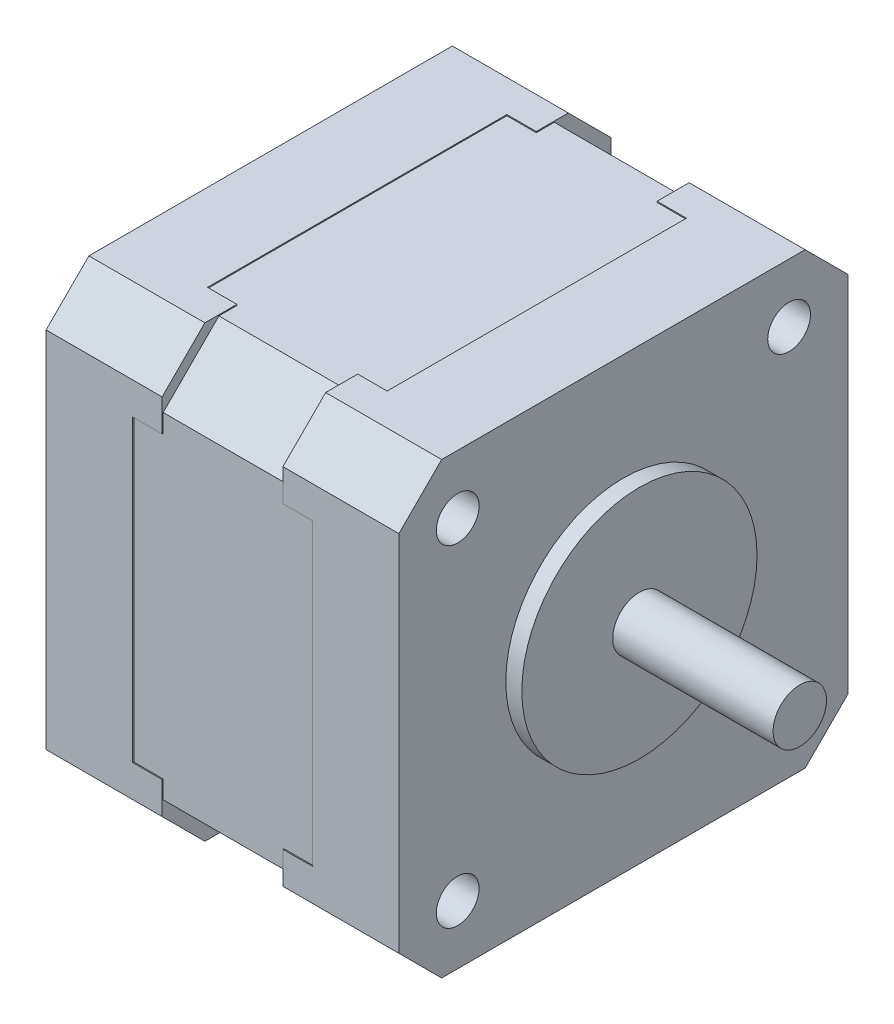
from build123d import *

# Parameters (mm, degrees)
CROQUIS1_W                  = 41.8
CROQUIS1_H                  = 41.8
SALIENTE_EXTRUIR1_DEPTH     = 11.3
CROQUIS2_W                  = 42
CROQUIS2_H                  = 41.9
SALIENTE_EXTRUIR2_DEPTH     = 10.85
CROQUIS3_W                  = 10.85
CROQUIS3_H                  = 42
SALIENTE_EXTRUIR3_DEPTH     = 0.1
CROQUIS4_W                  = 42
CROQUIS4_H                  = 42
SALIENTE_EXTRUIR4_DEPTH     = 10.85
CORTAR_EXTRUIR1_REACH       = 26.9
CROQUIS5_W                  = 0.1
CROQUIS5_H                  = 28
CORTAR_EXTRUIR2_REACH       = 26.9
CROQUIS6_W                  = 28
CROQUIS6_H                  = 0.1
CROQUIS7_W                  = 2.75
CROQUIS7_H                  = 28
CORTAR_EXTRUIR3_DEPTH       = 0.1
CROQUIS8_W                  = 2.75
CROQUIS8_H                  = 28
CORTAR_EXTRUIR4_DEPTH       = 0.1
CROQUIS9_W                  = 28
CROQUIS9_H                  = 0.1
CORTAR_EXTRUIR5_DEPTH       = 2.75
CROQUIS10_W                 = 2.75
CROQUIS10_H                 = 28
CORTAR_EXTRUIR6_DEPTH       = 0.1
CROQUIS11_W                 = 2.75
CROQUIS11_H                 = 28
CORTAR_EXTRUIR7_DEPTH       = 0.1
CROQUIS12_W                 = 2.75
CROQUIS12_H                 = 28
CORTAR_EXTRUIR8_DEPTH       = 0.1
CHAFL_N1_SIZE               = 5.214213562
CHAFL_N2_SIZE               = 4
CROQUIS18_R                 = 2
CORTAR_EXTRUIR10_DEPTH      = 6
CORTAR_EXTRUIR10_DEPTH_BACK = 3


with BuildPart() as part:
    # Croquis1 → Saliente-Extruir1 (new body)
    with BuildSketch(Plane(origin=(-5.65, 0, 0), x_dir=(0, -1, 0), z_dir=(-1, 0, 0))):
        Rectangle(CROQUIS1_W, CROQUIS1_H)
    extrude(amount=-SALIENTE_EXTRUIR1_DEPTH)

    # Croquis2 → Saliente-Extruir2 (add)
    with BuildSketch(Plane(origin=(5.65, 0, 0), x_dir=(0, 0, -1), z_dir=(1, 0, 0))):
        with Locations((0, -0.05)):
            Rectangle(CROQUIS2_W, CROQUIS2_H)
    extrude(amount=SALIENTE_EXTRUIR2_DEPTH)

    # Croquis3 → Saliente-Extruir3 (add)
    with BuildSketch(Plane(origin=(0, 20.9, 0), x_dir=(-1, 0, 0), z_dir=(0, 1, 0))):
        with Locations((-11.075, 0)):
            Rectangle(CROQUIS3_W, CROQUIS3_H)
    extrude(amount=SALIENTE_EXTRUIR3_DEPTH)

    # Croquis4 → Saliente-Extruir4 (add)
    with BuildSketch(Plane(origin=(-5.65, 0, 0), x_dir=(0, 0, -1), z_dir=(1, 0, 0))):
        Rectangle(CROQUIS4_W, CROQUIS4_H)
    extrude(amount=-SALIENTE_EXTRUIR4_DEPTH)

    # Croquis5 → Cortar-Extruir1 (cut, up to next)
    with BuildSketch(Plane(origin=(8.4, 0, 0), x_dir=(0, 0, -1), z_dir=(1, 0, 0)), mode=Mode.PRIVATE) as cortar_extruir1_sk1:
        with Locations((20.95, 0)):
            Rectangle(CROQUIS5_W, CROQUIS5_H)
    cortar_extruir1_tool1 = extrude(cortar_extruir1_sk1.sketch, amount=-CORTAR_EXTRUIR1_REACH, mode=Mode.PRIVATE) & part.part
    add(cortar_extruir1_tool1.solids().sort_by_distance((8.4, 0, -20.95))[0], mode=Mode.SUBTRACT)

    # Croquis6 → Cortar-Extruir2 (cut, up to next)
    with BuildSketch(Plane(origin=(-8.4, 0, 0), x_dir=(0, -1, 0), z_dir=(-1, 0, 0)), mode=Mode.PRIVATE) as cortar_extruir2_sk1:
        with Locations((0, 20.95)):
            Rectangle(CROQUIS6_W, CROQUIS6_H)
    cortar_extruir2_tool1 = extrude(cortar_extruir2_sk1.sketch, amount=-CORTAR_EXTRUIR2_REACH, mode=Mode.PRIVATE) & part.part
    add(cortar_extruir2_tool1.solids().sort_by_distance((-8.4, 0, 20.95))[0], mode=Mode.SUBTRACT)

    # Croquis7 → Cortar-Extruir3 (cut)
    with BuildSketch(Plane.XZ.offset(21)):
        with Locations((7.025, 0)):
            Rectangle(CROQUIS7_W, CROQUIS7_H)
    extrude(amount=-CORTAR_EXTRUIR3_DEPTH, mode=Mode.SUBTRACT)

    # Croquis8 → Cortar-Extruir4 (cut)
    with BuildSketch(Plane.XY.offset(21)):
        with Locations((7.025, 0)):
            Rectangle(CROQUIS8_W, CROQUIS8_H)
    extrude(amount=-CORTAR_EXTRUIR4_DEPTH, mode=Mode.SUBTRACT)

    # Croquis9 → Cortar-Extruir5 (cut)
    with BuildSketch(Plane.ZY.offset(-5.65)):
        with Locations((0, 20.95)):
            Rectangle(CROQUIS9_W, CROQUIS9_H)
    extrude(amount=-CORTAR_EXTRUIR5_DEPTH, mode=Mode.SUBTRACT)

    # Croquis10 → Cortar-Extruir6 (cut)
    with BuildSketch(Plane.XZ.offset(21)):
        with Locations((-7.025, 0)):
            Rectangle(CROQUIS10_W, CROQUIS10_H)
    extrude(amount=-CORTAR_EXTRUIR6_DEPTH, mode=Mode.SUBTRACT)

    # Croquis11 → Cortar-Extruir7 (cut)
    with BuildSketch(Plane(origin=(0, 0, -21), x_dir=(-1, 0, 0), z_dir=(0, 0, -1))):
        with Locations((7.025, 0)):
            Rectangle(CROQUIS11_W, CROQUIS11_H)
    extrude(amount=-CORTAR_EXTRUIR7_DEPTH, mode=Mode.SUBTRACT)

    # Croquis12 → Cortar-Extruir8 (cut)
    with BuildSketch(Plane(origin=(0, 21, 0), x_dir=(-1, 0, 0), z_dir=(0, 1, 0))):
        with Locations((7.025, 0)):
            Rectangle(CROQUIS12_W, CROQUIS12_H)
    extrude(amount=-CORTAR_EXTRUIR8_DEPTH, mode=Mode.SUBTRACT)

    # Croquis15 → Revolución1 (revolve)
    with BuildSketch(Plane.XY):
        Polygon((15.5, 11), (15.5, 0), (33, 0), (33, 2.5), (18, 2.5), (18, 11), align=None)
    revolve(axis=Axis((15.5, 0, 0), (1, 0, 0)))

    # Chaflán1
    chafl_n1_edges = [part.edges().sort_by_distance(p)[0] for p in [
        (0, -20.9, -20.9),
        (0, 20.9, 20.9),
        (0, 20.9, -20.9),
        (0, -20.9, 20.9),
    ]]
    chamfer(chafl_n1_edges, length=CHAFL_N1_SIZE)

    # Chaflán2
    chafl_n2_edges = [part.edges().sort_by_distance(p)[0] for p in [
        (11.075, -21, 21),
        (11.075, -21, -21),
        (11.075, 21, 21),
        (11.075, 21, -21),
        (-11.075, 21, -21),
        (-11.075, -21, -21),
        (-11.075, -21, 21),
        (-11.075, 21, 21),
    ]]
    chamfer(chafl_n2_edges, length=CHAFL_N2_SIZE)

    # Croquis18 → Cortar-Extruir10 (cut, two sides)
    with BuildSketch(Plane(origin=(12.45, 0, 0), x_dir=(0, 0, -1), z_dir=(1, 0, 0))) as cortar_extruir10_sk:
        with Locations((-15.5, 15.5)):
            Circle(CROQUIS18_R)
        with Locations((15.5, 15.5)):
            Circle(CROQUIS18_R)
        with Locations((15.5, -15.5)):
            Circle(CROQUIS18_R)
        with Locations((-15.5, -15.5)):
            Circle(CROQUIS18_R)
    extrude(amount=CORTAR_EXTRUIR10_DEPTH, mode=Mode.SUBTRACT)
    extrude(cortar_extruir10_sk.sketch, amount=-CORTAR_EXTRUIR10_DEPTH_BACK, mode=Mode.SUBTRACT)


solid = part.part
